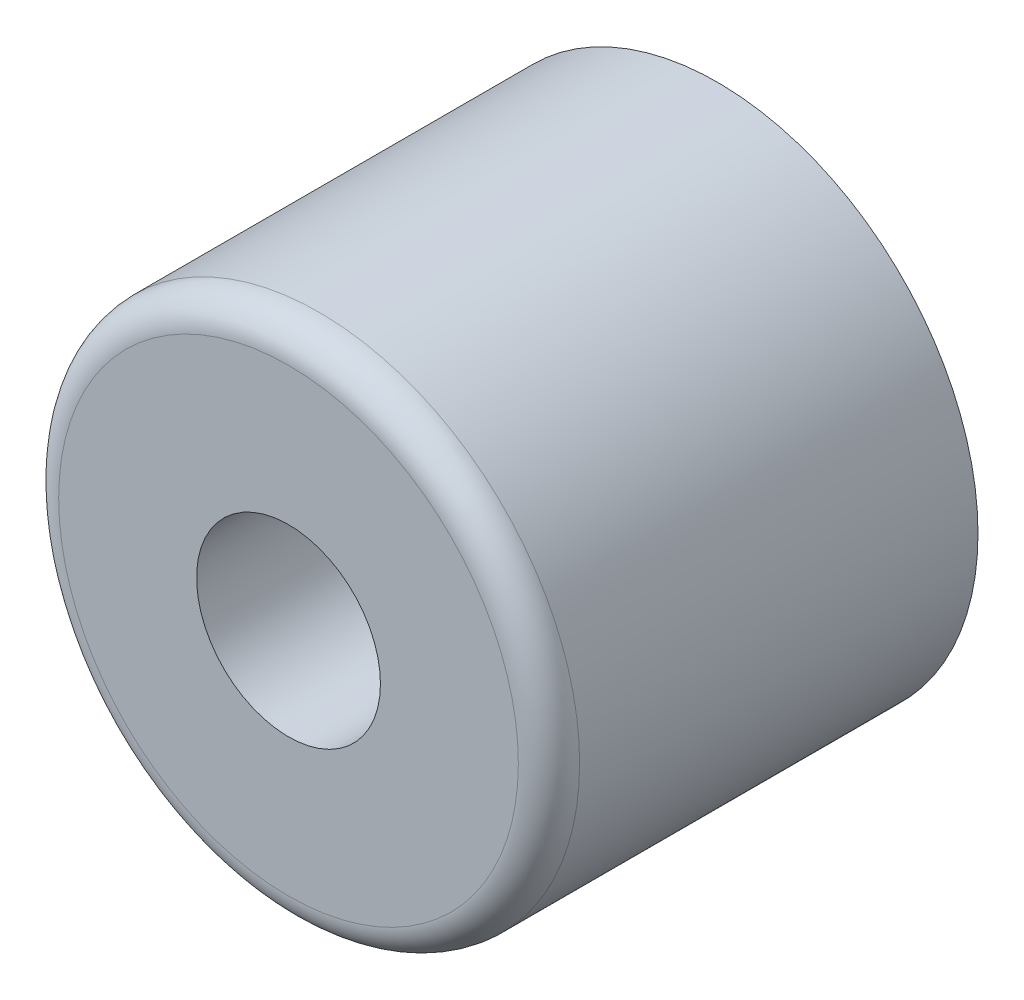
from build123d import *

# Parameters (mm, degrees)
SKETCH1_R           = 42.5
SKETCH1_R_2         = 15
BOSS_EXTRUDE1_DEPTH = 70
FILLET1_R           = 5


with BuildPart() as part:
    # Sketch1 → Boss-Extrude1 (new body)
    with BuildSketch(Plane.XY):
        Circle(SKETCH1_R)
        Circle(SKETCH1_R_2, mode=Mode.SUBTRACT)
    extrude(amount=BOSS_EXTRUDE1_DEPTH)

    # Fillet1
    fillet1_edges = [part.edges().sort_by_distance(p)[0] for p in [
        (-42.5, 0, 70),
    ]]
    fillet(fillet1_edges, radius=FILLET1_R)


solid = part.part
